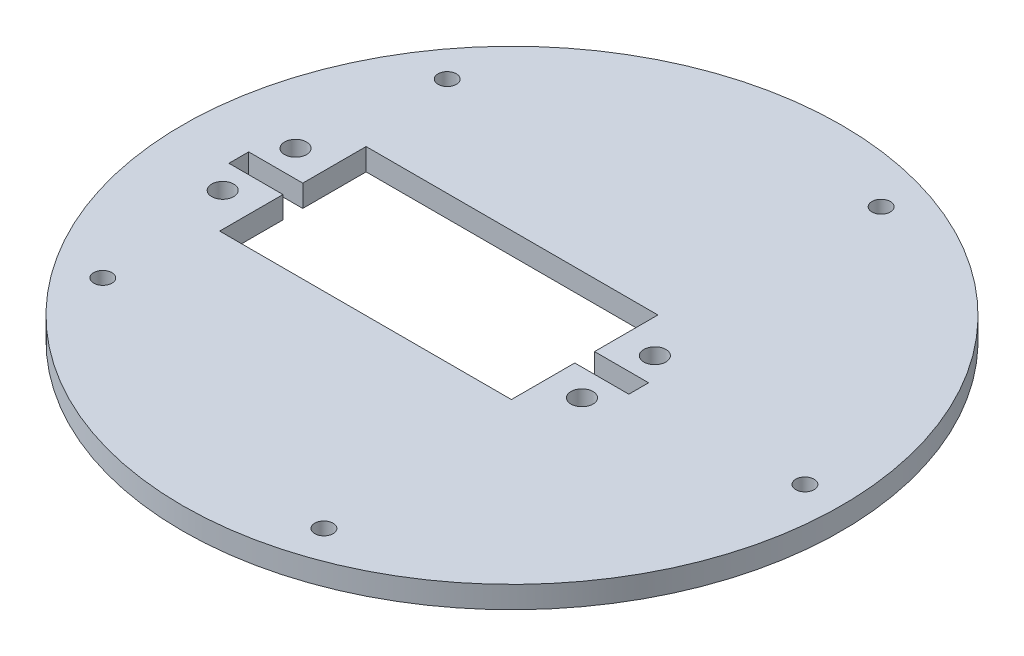
from build123d import *

# Parameters (mm, degrees)
SKETCH_1_R                   = 45
EXTRUDE_1_DEPTH              = 3
HOLE_WIZARD_M3_1_D           = 2.5
HOLE_WIZARD_M3_1_CSINK_D     = 2.55
HOLE_WIZARD_M3_1_CSINK_ANGLE = 90
SKETCH_7_R                   = 1.5
SKETCH_7_W                   = 7.385
SKETCH_7_H                   = 2.7
SKETCH_7_W_2                 = 39.84
SKETCH_7_H_2                 = 20
CUT_EXTRUDE_1_DEPTH          = 4
CUT_EXTRUDE_1_DEPTH_BACK     = 1


with BuildPart() as part:
    # 草图1 → 凸台-拉伸1 (new body)
    with BuildSketch(Plane(origin=(0, 0, 0), x_dir=(1, 0, 0), z_dir=(0, 1, 0))):
        Circle(SKETCH_1_R)
    extrude(amount=EXTRUDE_1_DEPTH)

    # M3 螺纹孔的螺纹孔钻头1 (through all)
    with Locations(Plane.XZ):
        with Locations((40, 0), (12.360679775, 38.042260652), (-32.360679775, 23.511410092), (-32.360679775, -23.511410092), (12.360679775, -38.042260652)):
            CounterSinkHole(HOLE_WIZARD_M3_1_D / 2, HOLE_WIZARD_M3_1_CSINK_D / 2, counter_sink_angle=HOLE_WIZARD_M3_1_CSINK_ANGLE)

    # 草图7 → 切除-拉伸1 (cut, two sides)
    with BuildSketch(Plane(origin=(0, 0, 0), x_dir=(1, 0, 0), z_dir=(0, 1, 0))) as cut_extrude_1_sk:
        with Locations((14.53, 4.975)):
            Circle(SKETCH_7_R)
        with Locations((14.53, -4.975)):
            Circle(SKETCH_7_R)
        with Locations((-34.53, 4.975)):
            Circle(SKETCH_7_R)
        with Locations((-34.53, -4.975)):
            Circle(SKETCH_7_R)
        with Locations((13.6125, 0)):
            Rectangle(SKETCH_7_W, SKETCH_7_H)
        with Locations((-33.6125, 0)):
            Rectangle(SKETCH_7_W, SKETCH_7_H)
        with Locations((-10, 0)):
            Rectangle(SKETCH_7_W_2, SKETCH_7_H_2)
    extrude(amount=CUT_EXTRUDE_1_DEPTH, mode=Mode.SUBTRACT)
    extrude(cut_extrude_1_sk.sketch, amount=-CUT_EXTRUDE_1_DEPTH_BACK, mode=Mode.SUBTRACT)


solid = part.part
